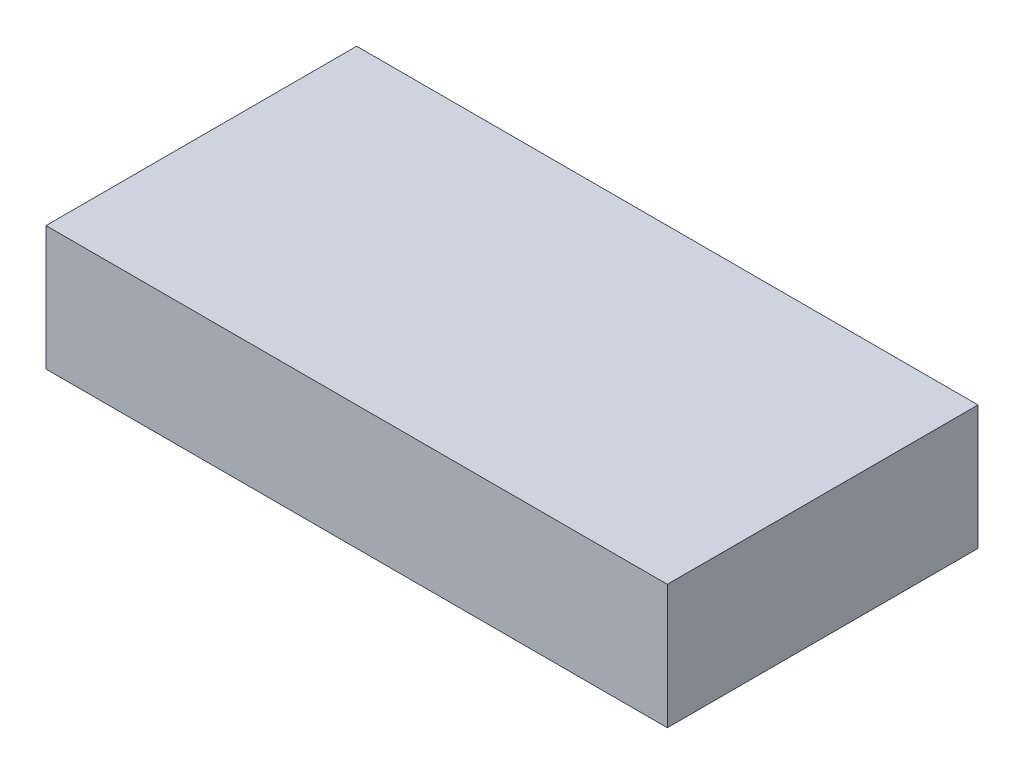
from build123d import *

# Parameters (mm, degrees)
SKETCH1_W           = 10
SKETCH1_H           = 5
BOSS_EXTRUDE1_DEPTH = 1
SKETCH1_3_W         = 10
SKETCH1_3_H         = 5
BOSS_EXTRUDE2_DEPTH = 1


with BuildPart() as part:
    # Sketch1 → Boss-Extrude1 (new body)
    with BuildSketch(Plane(origin=(0, 0, 0), x_dir=(1, 0, 0), z_dir=(0, 1, 0))):
        Rectangle(SKETCH1_W, SKETCH1_H)
    extrude(amount=BOSS_EXTRUDE1_DEPTH)

    # Sketch1_3 → Boss-Extrude2 (add)
    with BuildSketch(Plane(origin=(0, 0, 0), x_dir=(1, 0, 0), z_dir=(0, 1, 0))):
        Rectangle(SKETCH1_3_W, SKETCH1_3_H)
        Polygon((-2.5, -1.5), (-4, -1.5), (-4, 0), (-4, 1.5), (-2.5, 1.5), (2.5, 1.5), (4, 1.5), (4, 0), (4, -1.5), (2.5, -1.5), align=None, mode=Mode.SUBTRACT)
    extrude(amount=-BOSS_EXTRUDE2_DEPTH)


solid = part.part
